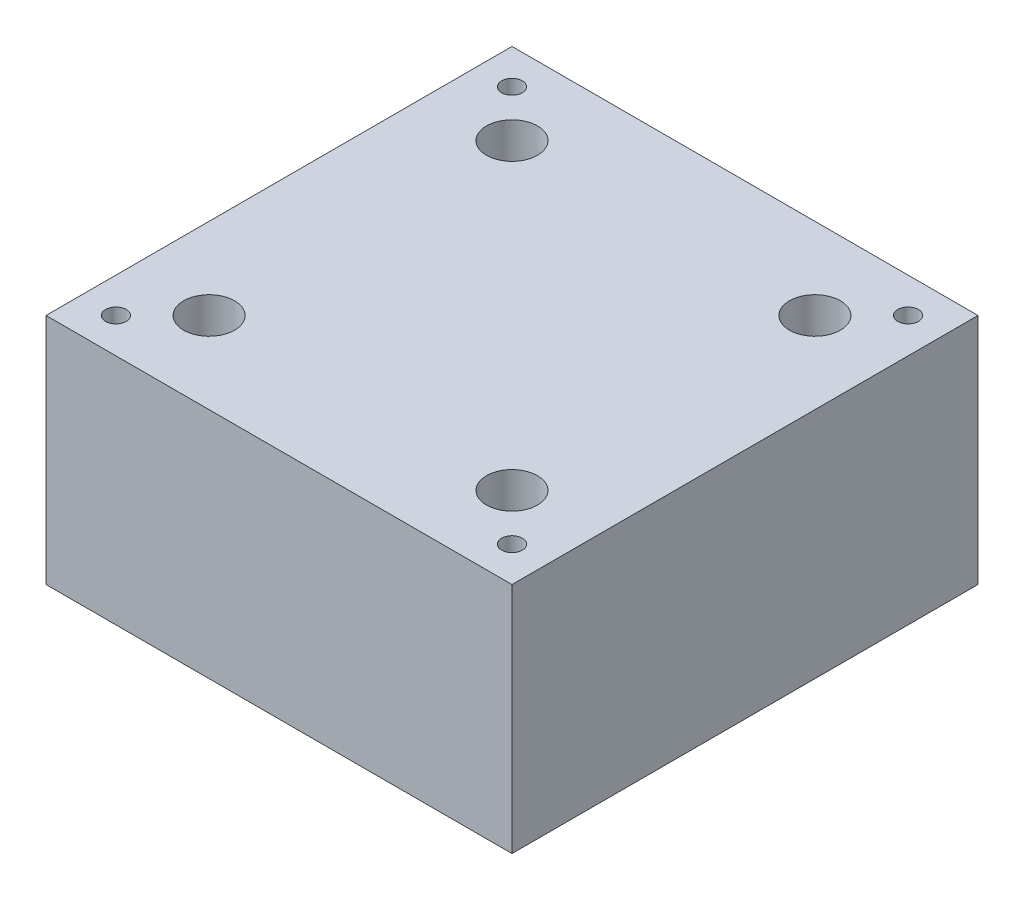
from build123d import *

# Parameters (mm, degrees)
SKETCH1_W                                      = 50.8
SKETCH1_H                                      = 50.8
BOSS_EXTRUDE1_DEPTH                            = 25.4
F_4_40_TAPPED_HOLE1_D                          = 2.2606
F_4_40_TAPPED_HOLE1_DEPTH                      = 20.2946
F_4_40_TAPPED_HOLE1_TIP                        = 0.679152758
CBORE_FOR_4_SOCKET_HEAD_CAP_SCREW1_D           = 3.2639
CBORE_FOR_4_SOCKET_HEAD_CAP_SCREW1_CBORE_D     = 5.55752
CBORE_FOR_4_SOCKET_HEAD_CAP_SCREW1_CBORE_DEPTH = 7.9248


with BuildPart() as part:
    # Sketch1 → Boss-Extrude1 (new body)
    with BuildSketch(Plane(origin=(0, 0, 0), x_dir=(1, 0, 0), z_dir=(0, 1, 0))):
        Rectangle(SKETCH1_W, SKETCH1_H)
    extrude(amount=BOSS_EXTRUDE1_DEPTH)

    # #4-40 Tapped Hole1
    with Locations(Plane(origin=(0, 25.4, 0), x_dir=(1, 0, 0), z_dir=(0, 1, 0))):
        with Locations((-21.59, 21.59), (21.59, 21.59), (21.59, -21.59), (-21.59, -21.59)):
            Hole(F_4_40_TAPPED_HOLE1_D / 2, depth=F_4_40_TAPPED_HOLE1_DEPTH)
            with Locations((0, 0, -(F_4_40_TAPPED_HOLE1_DEPTH + F_4_40_TAPPED_HOLE1_TIP / 2))):  # 118° drill point
                Cone(0, F_4_40_TAPPED_HOLE1_D / 2, F_4_40_TAPPED_HOLE1_TIP, mode=Mode.SUBTRACT)

    # CBORE for #4 Socket Head Cap Screw1 (through all)
    with Locations(Plane(origin=(0, 25.4, 0), x_dir=(1, 0, 0), z_dir=(0, 1, 0))):
        with Locations((-16.51, 16.51), (16.51, 16.51), (16.51, -16.51), (-16.51, -16.51)):
            CounterBoreHole(CBORE_FOR_4_SOCKET_HEAD_CAP_SCREW1_D / 2, CBORE_FOR_4_SOCKET_HEAD_CAP_SCREW1_CBORE_D / 2, CBORE_FOR_4_SOCKET_HEAD_CAP_SCREW1_CBORE_DEPTH)


solid = part.part
